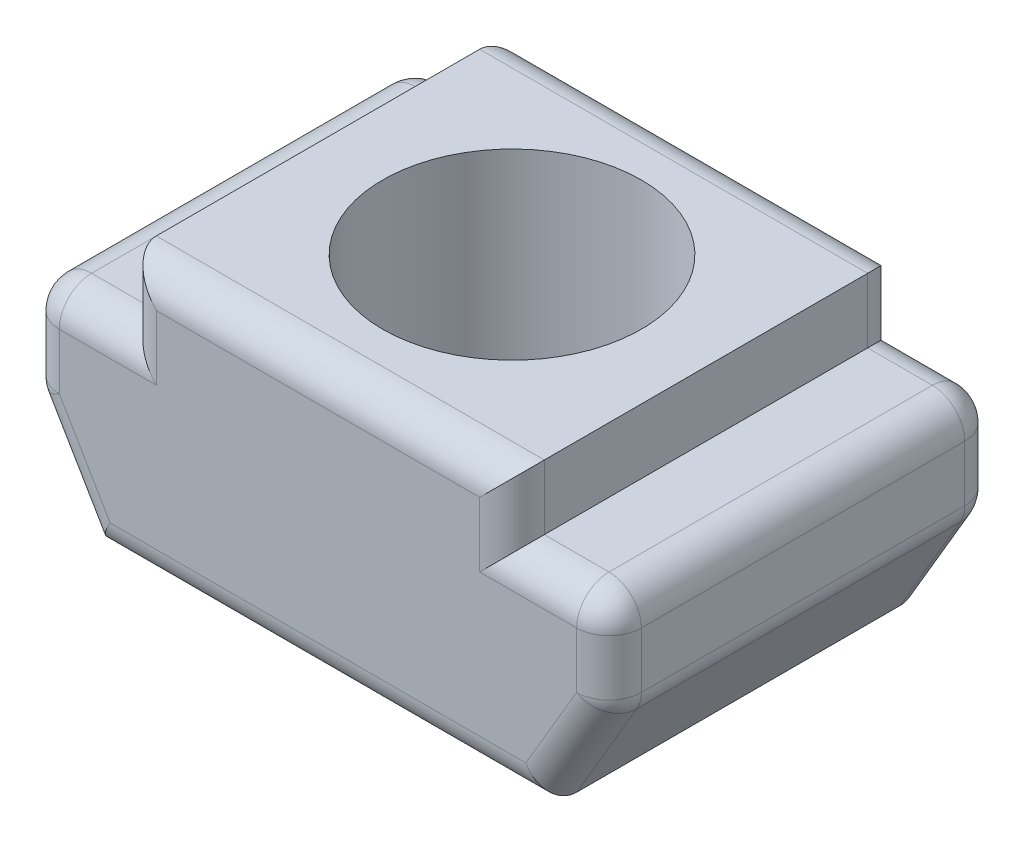
from build123d import *

# Parameters (mm, degrees)
SALIENTE_EXTRUIR2_DEPTH = 6
CROQUIS2_W              = 6
CROQUIS2_H              = 1
SALIENTE_EXTRUIR3_DEPTH = 6
CROQUIS3_R              = 2
CORTAR_EXTRUIR1_DEPTH   = 5.2
REDONDEO1_R             = 0.5


with BuildPart() as part:
    # Croquis1 → Saliente-Extruir2 (new body)
    with BuildSketch(Plane.XY):
        Polygon((0, 0), (-4.5, 0), (-4.5, -1.5), (-3.5, -3.2), (0, -3.2), align=None)
        Polygon((4.5, 0), (0, 0), (0, -3.2), (3.5, -3.2), (4.5, -1.5), align=None)
    extrude(amount=SALIENTE_EXTRUIR2_DEPTH)

    # Croquis2 → Saliente-Extruir3 (add)
    with BuildSketch(Plane.XY.offset(6)):
        with Locations((0, 0.5)):
            Rectangle(CROQUIS2_W, CROQUIS2_H)
    extrude(amount=-SALIENTE_EXTRUIR3_DEPTH)

    # Croquis3 → Cortar-Extruir1 (cut, through all)
    with BuildSketch(Plane(origin=(0, 1, 0), x_dir=(1, 0, 0), z_dir=(0, 1, 0))):
        with Locations((0, -3)):
            Circle(CROQUIS3_R)
    extrude(amount=-CORTAR_EXTRUIR1_DEPTH, mode=Mode.SUBTRACT)

    # Redondeo1
    redondeo1_edges = [part.edges().sort_by_distance(p)[0] for p in [
        (0, -3.2, 6),
        (-4.5, 0, 3),
        (4.5, 0, 3),
        (4.5, -1.5, 3),
        (-4.5, -1.5, 3),
        (4, -2.35, 6),
        (4.5, -0.75, 6),
        (3.75, 0, 0),
        (3.75, 0, 6),
        (-3, 0.5, 0),
        (0, 1, 6),
        (3, 0.5, 6),
        (0, 1, 0),
        (3, 0.5, 0),
        (-3.75, 0, 6),
        (-3, 0.5, 6),
        (-4.5, -0.75, 6),
        (-3.75, 0, 0),
        (4.5, -0.75, 0),
        (-4, -2.35, 6),
        (4, -2.35, 0),
        (0, -3.2, 0),
        (-4, -2.35, 0),
        (-4.5, -0.75, 0),
    ]]
    fillet(redondeo1_edges, radius=REDONDEO1_R)


solid = part.part
